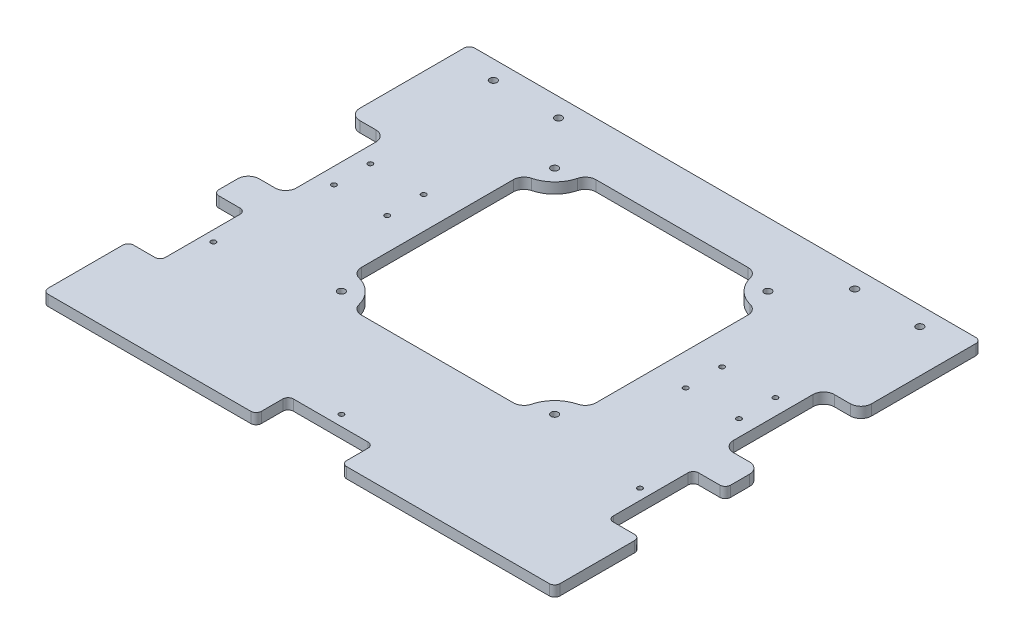
from build123d import *

# Parameters (mm, degrees)
SKETCH2_W                = 304.8
SKETCH2_H                = 254
BASE_DEPTH               = 6.35
SKETCH5_W                = 139.7
SKETCH5_H                = 139.7
FAN_CUTOUT_DEPTH         = 6.35
BOSS_EXTRUDE1_DEPTH      = 6.35
SKETCH8_R                = 2.15265
CUT_EXTRUDE1_DEPTH       = 6.35
FILLET2_R                = 6.35
SKETCH3_W                = 22.225
SKETCH3_H                = 60
WHEEL_CUTOUTS_DEPTH      = 6.35
WHEEL_FILLETS_R          = 6.35
SKETCH4_R                = 1.4732
SKETCH4_W                = 19.05
SKETCH4_H                = 50.8
SKETCH4_W_2              = 50.8
SKETCH4_H_2              = 19.05
ULTRASONIC_CUTOUTS_DEPTH = 6.35
ULTRASONIC_FILLETS_R     = 3.175
FILLET3_R                = 3.175
SKETCH9_R                = 2.15265
CUT_EXTRUDE2_DEPTH       = 6.35
SKETCH10_R               = 1.4732
CUT_EXTRUDE3_DEPTH       = 6.35


with BuildPart() as part:
    # Sketch2 → Base (new body)
    with BuildSketch(Plane(origin=(0, 0, 0), x_dir=(1, 0, 0), z_dir=(0, 1, 0))):
        with Locations((0, -25.4)):
            Rectangle(SKETCH2_W, SKETCH2_H)
    extrude(amount=BASE_DEPTH)

    # Sketch5 → Fan Cutout (cut)
    with BuildSketch(Plane(origin=(0, 6.35, 0), x_dir=(1, 0, 0), z_dir=(0, 1, 0))):
        Rectangle(SKETCH5_W, SKETCH5_H)
    extrude(amount=-FAN_CUTOUT_DEPTH, mode=Mode.SUBTRACT)

    # Sketch7 → Boss-Extrude1 (add)
    with BuildSketch(Plane(origin=(0, 6.35, 0), x_dir=(1, 0, 0), z_dir=(0, 1, 0))):
        with BuildLine():
            Line((-69.85, 50.8), (-69.85, 69.85))
            Line((-69.85, 69.85), (-50.8, 69.85))
            ThreePointArc((-50.8, 69.85), (-56.379615818, 56.379615818), (-69.85, 50.8))
        make_face()
        with BuildLine():
            Line((50.8, 69.85), (69.85, 69.85))
            Line((69.85, 69.85), (69.85, 50.8))
            ThreePointArc((69.85, 50.8), (56.379615818, 56.379615818), (50.8, 69.85))
        make_face()
        with BuildLine():
            Line((-69.85, -50.8), (-69.85, -69.85))
            Line((-69.85, -69.85), (-50.8, -69.85))
            ThreePointArc((-50.8, -69.85), (-56.379615818, -56.379615818), (-69.85, -50.8))
        make_face()
        with BuildLine():
            Line((50.8, -69.85), (69.85, -69.85))
            Line((69.85, -69.85), (69.85, -50.8))
            ThreePointArc((69.85, -50.8), (56.379615818, -56.379615818), (50.8, -69.85))
        make_face()
    extrude(amount=-BOSS_EXTRUDE1_DEPTH)

    # Sketch8 → Cut-Extrude1 (cut)
    with BuildSketch(Plane(origin=(0, 6.35, 0), x_dir=(1, 0, 0), z_dir=(0, 1, 0))):
        with Locations((-63.5, 63.5)):
            Circle(SKETCH8_R)
        with Locations((63.5, 63.5)):
            Circle(SKETCH8_R)
        with Locations((63.5, -63.5)):
            Circle(SKETCH8_R)
        with Locations((-63.5, -63.5)):
            Circle(SKETCH8_R)
    extrude(amount=-CUT_EXTRUDE1_DEPTH, mode=Mode.SUBTRACT)

    # Fillet2
    fillet2_edges = [part.edges().sort_by_distance(p)[0] for p in [
        (-69.85, 3.175, -50.8),
        (-50.8, 3.175, -69.85),
        (50.8, 3.175, -69.85),
        (69.85, 3.175, -50.8),
        (-50.8, 3.175, 69.85),
        (-69.85, 3.175, 50.8),
        (69.85, 3.175, 50.8),
        (50.8, 3.175, 69.85),
    ]]
    fillet(fillet2_edges, radius=FILLET2_R)

    # Sketch3 → Wheel Cutouts (cut)
    with BuildSketch(Plane(origin=(0, 6.35, 0), x_dir=(1, 0, 0), z_dir=(0, 1, 0))):
        with Locations((-141.2875, 0)):
            Rectangle(SKETCH3_W, SKETCH3_H)
        with Locations((141.2875, 0)):
            Rectangle(SKETCH3_W, SKETCH3_H)
    extrude(amount=-WHEEL_CUTOUTS_DEPTH, mode=Mode.SUBTRACT)

    # Wheel Fillets
    wheel_fillets_edges = [part.edges().sort_by_distance(p)[0] for p in [
        (-130.175, 3.175, 30),
        (-130.175, 3.175, -30),
        (-152.4, 3.175, -30),
        (-152.4, 3.175, 30),
        (130.175, 3.175, -30),
        (130.175, 3.175, 30),
        (152.4, 3.175, 30),
        (152.4, 3.175, -30),
    ]]
    fillet(wheel_fillets_edges, radius=WHEEL_FILLETS_R)

    # Sketch4 → Ultrasonic Cutouts (cut)
    with BuildSketch(Plane(origin=(0, 6.35, 0), x_dir=(1, 0, 0), z_dir=(0, 1, 0))):
        with Locations((-127, -76.2)):
            Circle(SKETCH4_R)
        with Locations((127, -76.2)):
            Circle(SKETCH4_R)
        with Locations((0, -127)):
            Circle(SKETCH4_R)
        with Locations((-142.875, -76.2)):
            Rectangle(SKETCH4_W, SKETCH4_H)
        with Locations((142.875, -76.2)):
            Rectangle(SKETCH4_W, SKETCH4_H)
        with Locations((0, -142.875)):
            Rectangle(SKETCH4_W_2, SKETCH4_H_2)
    extrude(amount=-ULTRASONIC_CUTOUTS_DEPTH, mode=Mode.SUBTRACT)

    # Ultrasonic Fillets
    ultrasonic_fillets_edges = [part.edges().sort_by_distance(p)[0] for p in [
        (-133.35, 3.175, 101.6),
        (-133.35, 3.175, 50.8),
        (-152.4, 3.175, 50.8),
        (-152.4, 3.175, 101.6),
        (133.35, 3.175, 50.8),
        (133.35, 3.175, 101.6),
        (152.4, 3.175, 101.6),
        (152.4, 3.175, 50.8),
        (25.4, 3.175, 152.4),
        (25.4, 3.175, 133.35),
        (-25.4, 3.175, 133.35),
        (-25.4, 3.175, 152.4),
    ]]
    fillet(ultrasonic_fillets_edges, radius=ULTRASONIC_FILLETS_R)

    # Fillet3
    fillet3_edges = [part.edges().sort_by_distance(p)[0] for p in [
        (-152.4, 3.175, -101.6),
        (152.4, 3.175, -101.6),
        (152.4, 3.175, 152.4),
        (-152.4, 3.175, 152.4),
    ]]
    fillet(fillet3_edges, radius=FILLET3_R)

    # Sketch9 → Cut-Extrude2 (cut)
    with BuildSketch(Plane(origin=(0, 6.35, 0), x_dir=(1, 0, 0), z_dir=(0, 1, 0))):
        with Locations((-127, 90.4875)):
            Circle(SKETCH9_R)
        with Locations((-88.2, 90.4875)):
            Circle(SKETCH9_R)
        with Locations((88.2, 90.4875)):
            Circle(SKETCH9_R)
        with Locations((127, 90.4875)):
            Circle(SKETCH9_R)
    extrude(amount=-CUT_EXTRUDE2_DEPTH, mode=Mode.SUBTRACT)

    # Sketch10 → Cut-Extrude3 (cut)
    with BuildSketch(Plane(origin=(0, 6.35, 0), x_dir=(1, 0, 0), z_dir=(0, 1, 0))):
        with Locations((-120.625, 10.85)):
            Circle(SKETCH10_R)
        with Locations((-88.875, 10.85)):
            Circle(SKETCH10_R)
        with Locations((-120.625, -10.85)):
            Circle(SKETCH10_R)
        with Locations((-88.875, -10.85)):
            Circle(SKETCH10_R)
        with Locations((88.875, 10.85)):
            Circle(SKETCH10_R)
        with Locations((120.625, 10.85)):
            Circle(SKETCH10_R)
        with Locations((88.875, -10.85)):
            Circle(SKETCH10_R)
        with Locations((120.625, -10.85)):
            Circle(SKETCH10_R)
    extrude(amount=-CUT_EXTRUDE3_DEPTH, mode=Mode.SUBTRACT)


solid = part.part
